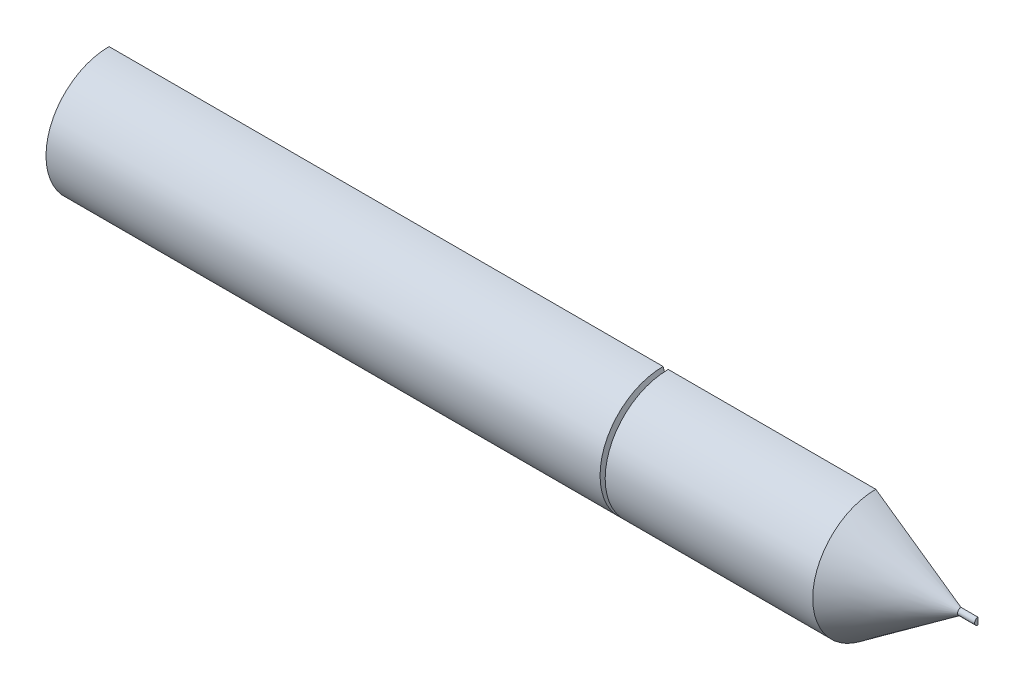
from build123d import *

# Parameters (mm, degrees)
SKETCH5_R          = 0.5
CUT_EXTRUDE1_DEPTH = 10
SKETCH6_W          = 703.629675086
SKETCH6_H          = 157.863240862
CUT_EXTRUDE2_DEPTH = 90


with BuildPart() as part:
    # Sketch1 → Revolve1 (revolve)
    with BuildSketch(Plane.XY):
        Polygon((-315, 2), (-315, 37), (135, 37), (184.985180236, 2), (194.985180236, 2), (194.985180236, 0), (-125, 0), (-325, 0), (-325, 2), align=None)
    revolve(axis=Axis((-125, 0, 0), (1, 0, 0)))


with BuildPart() as body_2:
    # Sketch4 → Revolve2 (revolve)
    with BuildSketch(Plane(origin=(0, 0, 0), x_dir=(1, 0, 0), z_dir=(0, 1, 0))):
        Polygon((23, 0), (23, 10), (13.172803675, 37), (10.172803675, 37), (20, 10), (20, 0), align=None)
    revolve(axis=Axis((20, 0, 0), (1, 0, 0)))

    # Sketch5 → Cut-Extrude1 (cut)
    with BuildSketch(Plane.ZY.offset(-20)):
        Circle(SKETCH5_R)
    extrude(amount=-CUT_EXTRUDE1_DEPTH, mode=Mode.SUBTRACT)


with BuildPart() as part_1:
    add(part.part)

    # Combine1: cut body 2
    add(body_2.part, mode=Mode.SUBTRACT)

    # Sketch6 → Cut-Extrude2 (cut)
    with BuildSketch(Plane.XY):
        Rectangle(SKETCH6_W, SKETCH6_H)
    extrude(amount=-CUT_EXTRUDE2_DEPTH, mode=Mode.SUBTRACT)


solid = part_1.part
